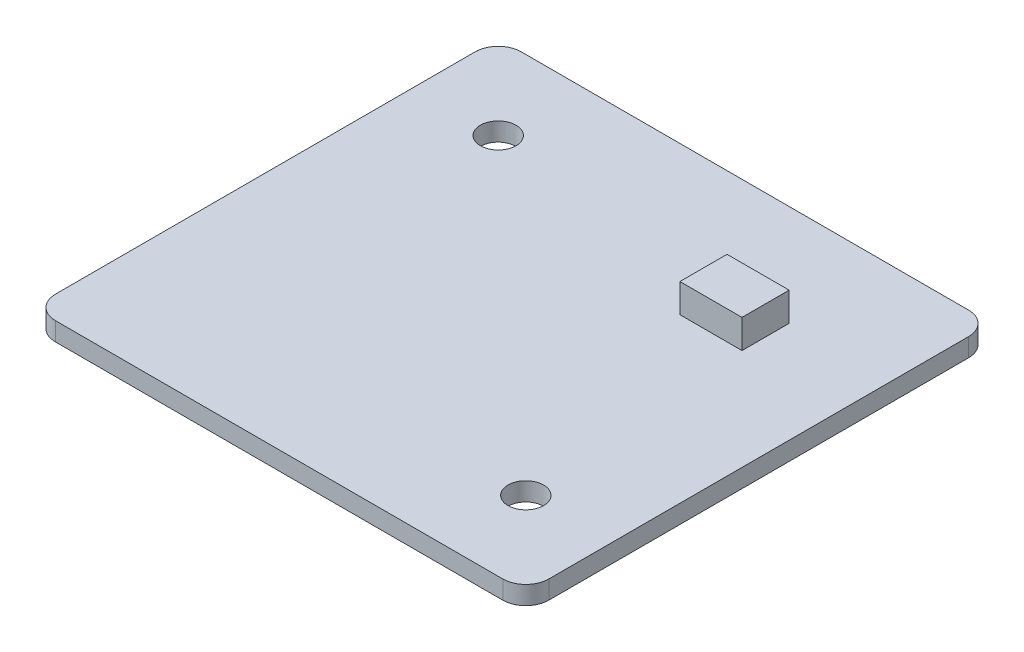
from build123d import *

# Parameters (mm, degrees)
SKETCH1_W           = 42.9
SKETCH1_H           = 40.5
SKETCH1_R           = 1.55
BOSS_EXTRUDE1_DEPTH = 1.6
FILLET1_R           = 2
SKETCH2_W           = 5.4
SKETCH2_H           = 4.1
BOSS_EXTRUDE2_DEPTH = 2.5
SKETCH3_W           = 20.5
SKETCH3_H           = 2.56
BOSS_EXTRUDE3_DEPTH = 2.3


with BuildPart() as part:
    # Sketch1 → Boss-Extrude1 (new body)
    with BuildSketch(Plane(origin=(0, 0, 0), x_dir=(1, 0, 0), z_dir=(0, 1, 0))):
        with Locations((-8.819274306, 9.105101592)):
            Rectangle(SKETCH1_W, SKETCH1_H)
        with Locations((-22.969274306, 22.055101592)):
            Circle(SKETCH1_R, mode=Mode.SUBTRACT)
        with Locations((5.330725694, -3.844898408)):
            Circle(SKETCH1_R, mode=Mode.SUBTRACT)
    extrude(amount=BOSS_EXTRUDE1_DEPTH)

    # Fillet1
    fillet1_edges = [part.edges().sort_by_distance(p)[0] for p in [
        (-30.269274306, 0.8, -29.355101592),
        (12.630725694, 0.8, -29.355101592),
        (12.630725694, 0.8, 11.144898408),
        (-30.269274306, 0.8, 11.144898408),
    ]]
    fillet(fillet1_edges, radius=FILLET1_R)

    # Sketch2 → Boss-Extrude2 (add)
    with BuildSketch(Plane(origin=(0, 1.6, 0), x_dir=(1, 0, 0), z_dir=(0, 1, 0))):
        with Locations((1.130725694, 18.505101592)):
            Rectangle(SKETCH2_W, SKETCH2_H)
    extrude(amount=BOSS_EXTRUDE2_DEPTH)

    # Sketch3 → Boss-Extrude3 (add)
    with BuildSketch(Plane.XZ):
        with Locations((-11.419274306, 4.614898408)):
            Rectangle(SKETCH3_W, SKETCH3_H)
    extrude(amount=BOSS_EXTRUDE3_DEPTH)


solid = part.part
